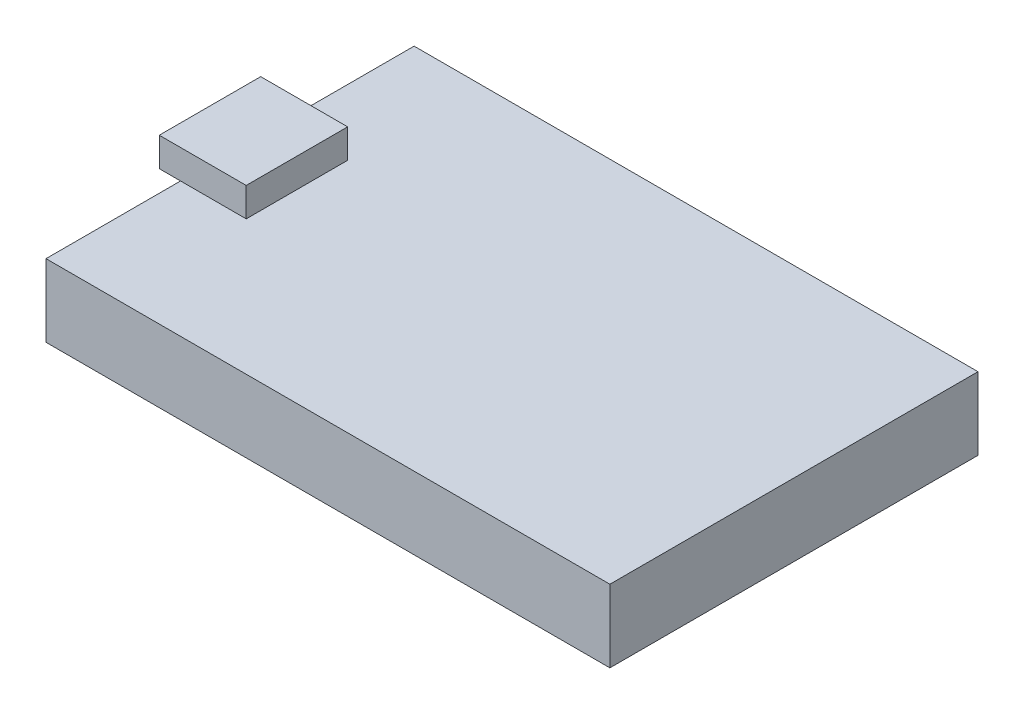
from build123d import *

# Parameters (mm, degrees)
SKETCH1_W           = 38.91
SKETCH1_H           = 25.4
BOSS_EXTRUDE1_DEPTH = 5
SKETCH2_W           = 6
SKETCH2_H           = 7
BOSS_EXTRUDE2_DEPTH = 2


with BuildPart() as part:
    # Sketch1 → Boss-Extrude1 (new body)
    with BuildSketch(Plane(origin=(0, 0, 0), x_dir=(1, 0, 0), z_dir=(0, 1, 0))):
        Rectangle(SKETCH1_W, SKETCH1_H)
    extrude(amount=BOSS_EXTRUDE1_DEPTH)

    # Sketch2 → Boss-Extrude2 (add)
    with BuildSketch(Plane(origin=(1.710032879, 5, 0), x_dir=(1, 0, 0), z_dir=(0, 1, 0))):
        with Locations((-19.633959391, 0.083952817)):
            Rectangle(SKETCH2_W, SKETCH2_H)
    extrude(amount=BOSS_EXTRUDE2_DEPTH)


solid = part.part
